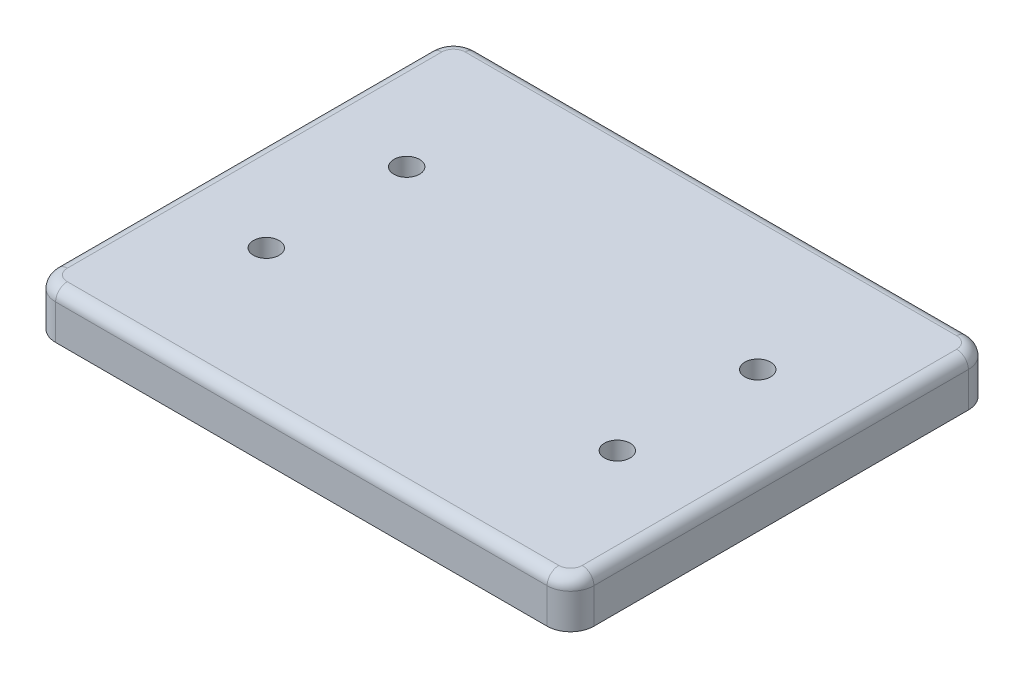
from build123d import *

# Parameters (mm, degrees)
SKETCH1_R            = 11
BOSS_EXTRUDE1_DEPTH  = 40
FILLET1_R            = 10
SKETCH2_R            = 18
CUT_EXTRUDE1_DEPTH   = 20
LPATTERN1_COUNT      = 2
LPATTERN1_PITCH      = 300
LPATTERN1_COUNT_DIR2 = 2
LPATTERN1_PITCH_DIR2 = 120


with BuildPart() as part:
    # Sketch1 → Boss-Extrude1 (new body)
    with BuildSketch(Plane(origin=(0, 0, 0), x_dir=(1, 0, 0), z_dir=(0, 1, 0))):
        with BuildLine():
            Line((-210, -180), (210, -180))
            ThreePointArc((210, -180), (224.142135624, -174.142135624), (230, -160))
            Line((230, -160), (230, 160))
            ThreePointArc((230, 160), (224.142135624, 174.142135624), (210, 180))
            Line((210, 180), (-210, 180))
            ThreePointArc((-210, 180), (-224.142135624, 174.142135624), (-230, 160))
            Line((-230, 160), (-230, -160))
            ThreePointArc((-230, -160), (-224.142135624, -174.142135624), (-210, -180))
        make_face()
        with Locations((-150, 60)):
            Circle(SKETCH1_R, mode=Mode.SUBTRACT)
        with Locations((-150, -60)):
            Circle(SKETCH1_R, mode=Mode.SUBTRACT)
        with Locations((150, -60)):
            Circle(SKETCH1_R, mode=Mode.SUBTRACT)
        with Locations((150, 60)):
            Circle(SKETCH1_R, mode=Mode.SUBTRACT)
    extrude(amount=BOSS_EXTRUDE1_DEPTH)

    # Fillet1
    fillet1_edges = [part.edges().sort_by_distance(p)[0] for p in [
        (224.142135624, 40, 174.142135624),
        (230, 40, 0),
        (224.142135624, 40, -174.142135624),
        (0, 40, -180),
        (-224.142135624, 40, -174.142135624),
        (-230, 40, 0),
        (-224.142135624, 40, 174.142135624),
        (0, 40, 180),
    ]]
    fillet(fillet1_edges, radius=FILLET1_R)

    # Sketch2 → Cut-Extrude1 (cut)
    with BuildSketch(Plane.XZ):
        with Locations((-150, 60)):
            Circle(SKETCH2_R)
    cut_extrude1 = extrude(amount=-CUT_EXTRUDE1_DEPTH, mode=Mode.SUBTRACT)

    # LPattern1: Cut-Extrude1 2 × 2
    with Locations(*[(i * LPATTERN1_PITCH, 0, -j * LPATTERN1_PITCH_DIR2) for i in range(LPATTERN1_COUNT) for j in range(LPATTERN1_COUNT_DIR2) if (i, j) != (0, 0)]):
        add(cut_extrude1, mode=Mode.SUBTRACT)


solid = part.part
